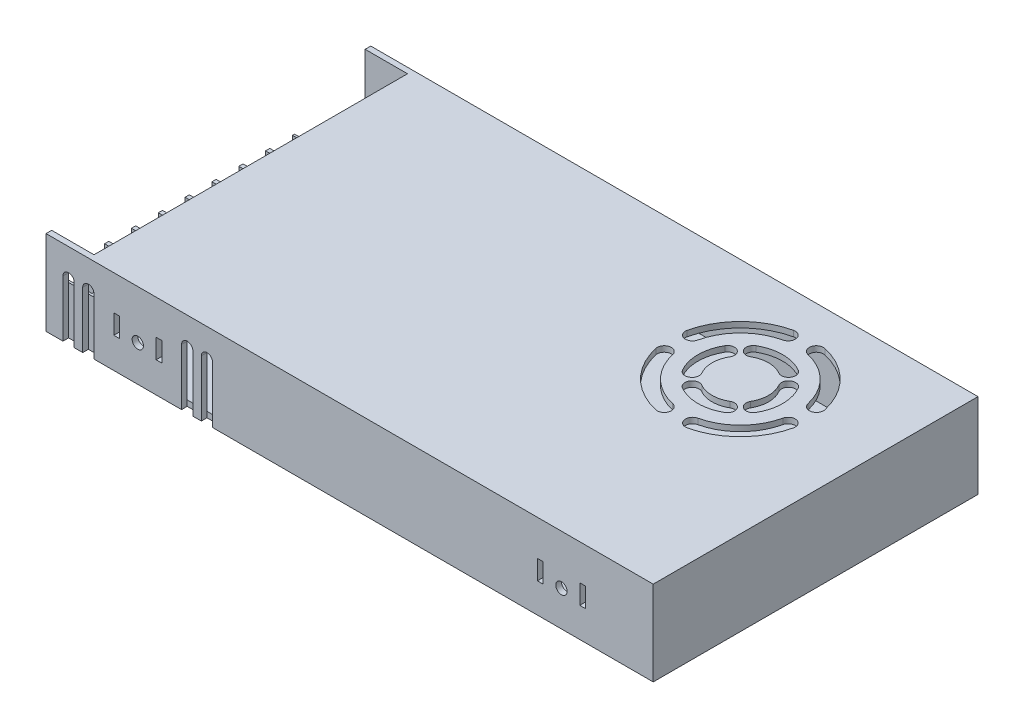
from build123d import *

# Parameters (mm, degrees)
SKETCH1_W              = 215
SKETCH1_H              = 115
BOSS_EXTRUDE1_DEPTH    = 30
SHELL1_T               = -2
CUT_EXTRUDE1_DEPTH     = 28
CIRPATTERN1_COUNT      = 4
SKETCH3_W              = 15
SKETCH3_H              = 111
CUT_EXTRUDE2_DEPTH     = 10
CUT_EXTRUDE3_START     = -20
SKETCH4_R              = 2
CUT_EXTRUDE3_DEPTH     = 11
SKETCH5_W              = 14.5
SKETCH5_H              = 9.5
BOSS_EXTRUDE2_DEPTH    = 15
SKETCH6_W              = 13
SKETCH6_H              = 8
CUT_EXTRUDE4_DEPTH     = 10
SKETCH7_W              = 12
SKETCH7_H              = 7.5
BOSS_EXTRUDE3_DEPTH    = 1
SKETCH8_R              = 3
BOSS_EXTRUDE4_DEPTH    = 2
FILLET1_R              = 1
LPATTERN1_COUNT        = 9
LPATTERN1_PITCH        = 9.5
FILLET1_OF_LPATTERN1_R = 1
SKETCH9_R              = 2
SKETCH9_W              = 2
SKETCH9_H              = 6.9
SKETCH9_W_2            = 2.056016159
CUT_EXTRUDE5_DEPTH     = 2


with BuildPart() as part:
    # Sketch1 → Boss-Extrude1 (new body)
    with BuildSketch(Plane(origin=(0, 0, 0), x_dir=(1, 0, 0), z_dir=(0, 1, 0))):
        Rectangle(SKETCH1_W, SKETCH1_H)
    extrude(amount=BOSS_EXTRUDE1_DEPTH)

    # Shell1
    shell1_openings = [part.faces().sort_by_distance(p)[0] for p in [
        (-107.5, 15, 0),
    ]]
    offset(amount=SHELL1_T, openings=shell1_openings, kind=Kind.INTERSECTION)

    # Sketch2 → Cut-Extrude1 (cut)
    with BuildSketch(Plane(origin=(0, 30, 0), x_dir=(1, 0, 0), z_dir=(0, 1, 0))):
        with BuildLine():
            ThreePointArc((67.55, 33.790381057), (60.05, 35.8), (52.55, 33.790381057))
            ThreePointArc((52.55, 33.790381057), (51.634936491, 30.375317547), (55.05, 29.460254038))
            ThreePointArc((55.05, 29.460254038), (60.05, 30.8), (65.05, 29.460254038))
            ThreePointArc((65.05, 29.460254038), (68.465063509, 30.375317547), (67.55, 33.790381057))
        make_face()
        with BuildLine():
            ThreePointArc((54.494444444, 45.174901076), (42.37233047, 38.47766953), (35.675098924, 26.355555556))
            ThreePointArc((35.675098924, 26.355555556), (37.557033476, 23.362509892), (40.550079139, 25.244444444))
            ThreePointArc((40.550079139, 25.244444444), (45.907864376, 34.942135624), (55.605555556, 40.299920861))
            ThreePointArc((55.605555556, 40.299920861), (57.487490108, 43.292966524), (54.494444444, 45.174901076))
        make_face()
    cut_extrude1 = extrude(amount=-CUT_EXTRUDE1_DEPTH, mode=Mode.SUBTRACT)

    # CirPattern1: Cut-Extrude1 ×4 about axis
    cirpattern1_axis = Axis((60.05, 0, -20.8), (0, 1, 0))
    for i in range(1, CIRPATTERN1_COUNT):
        add(cut_extrude1.rotate(cirpattern1_axis, i * 360 / CIRPATTERN1_COUNT), mode=Mode.SUBTRACT)

    # Sketch3 → Cut-Extrude2 (cut)
    with BuildSketch(Plane(origin=(0, 30, 0), x_dir=(1, 0, 0), z_dir=(0, 1, 0))):
        with Locations((-100, 0)):
            Rectangle(SKETCH3_W, SKETCH3_H)
    extrude(amount=-CUT_EXTRUDE2_DEPTH, mode=Mode.SUBTRACT)

    # Sketch4 → Cut-Extrude3 (cut, through all)
    with BuildSketch(Plane(origin=(0, 30, 0), x_dir=(1, 0, 0), z_dir=(0, 1, 0)).offset(CUT_EXTRUDE3_START)):
        with Locations((-75, 25)):
            Circle(SKETCH4_R)
        with Locations((-75, -25)):
            Circle(SKETCH4_R)
        with Locations((75, -25)):
            Circle(SKETCH4_R)
        with Locations((75, 25)):
            Circle(SKETCH4_R)
    extrude(amount=-CUT_EXTRUDE3_DEPTH, mode=Mode.SUBTRACT)

    # Sketch5 → Boss-Extrude2 (add)
    with BuildSketch(Plane(origin=(0, 2, 0), x_dir=(1, 0, 0), z_dir=(0, 1, 0))):
        with Locations((-99.75, -50.75)):
            Rectangle(SKETCH5_W, SKETCH5_H)
    boss_extrude2 = extrude(amount=BOSS_EXTRUDE2_DEPTH)

    # Sketch6 → Cut-Extrude4 (cut)
    with BuildSketch(Plane(origin=(0, 17, 0), x_dir=(1, 0, 0), z_dir=(0, 1, 0))):
        with Locations((-100.5, -50.75)):
            Rectangle(SKETCH6_W, SKETCH6_H)
    cut_extrude4 = extrude(amount=-CUT_EXTRUDE4_DEPTH, mode=Mode.SUBTRACT)

    # Sketch7 → Boss-Extrude3 (add)
    with BuildSketch(Plane(origin=(0, 7, 0), x_dir=(1, 0, 0), z_dir=(0, 1, 0))):
        with Locations((-100.5, -50.75)):
            Rectangle(SKETCH7_W, SKETCH7_H)
    boss_extrude3 = extrude(amount=BOSS_EXTRUDE3_DEPTH)

    # Sketch8 → Boss-Extrude4 (add)
    with BuildSketch(Plane(origin=(0, 8, 0), x_dir=(1, 0, 0), z_dir=(0, 1, 0))):
        with Locations((-100.5, -50.75)):
            Circle(SKETCH8_R)
    boss_extrude4 = extrude(amount=BOSS_EXTRUDE4_DEPTH)

    # Fillet1
    fillet1_edges = [part.edges().sort_by_distance(p)[0] for p in [
        (-103.5, 10, 50.75),
    ]]
    fillet(fillet1_edges, radius=FILLET1_R)

    # LPattern1: Boss-Extrude2, Cut-Extrude4, Boss-Extrude3, Boss-Extrude4 ×9
    with Locations(*[(0, 0, -i * LPATTERN1_PITCH) for i in range(1, LPATTERN1_COUNT)]):
        add(boss_extrude2)
        add(cut_extrude4, mode=Mode.SUBTRACT)
        add(boss_extrude3)
        add(boss_extrude4)

    # Fillet1 of LPattern1
    fillet1_of_lpattern1_edges = [part.edges().sort_by_distance(p)[0] for p in [
        (-103.5, 10, 41.25),
        (-103.5, 10, 31.75),
        (-103.5, 10, 22.25),
        (-103.5, 10, 12.75),
        (-103.5, 10, 3.25),
        (-103.5, 10, -6.25),
        (-103.5, 10, -15.75),
        (-103.5, 10, -25.25),
    ]]
    fillet(fillet1_of_lpattern1_edges, radius=FILLET1_OF_LPATTERN1_R)

    # Sketch9 → Cut-Extrude5 (cut)
    with BuildSketch(Plane.XY.offset(57.5)):
        with Locations((-75, 12.8)):
            Circle(SKETCH9_R)
        with Locations((75, 12.5)):
            Circle(SKETCH9_R)
        with BuildLine():
            Line((-101.5, 0), (-101.5, 20))
            ThreePointArc((-101.5, 20), (-99.5, 22), (-97.5, 20))
            Line((-97.5, 20), (-97.5, 0))
            Line((-97.5, 0), (-101.5, 0))
        make_face()
        with BuildLine():
            Line((-94.5, 0), (-90.5, 0))
            Line((-90.5, 0), (-90.5, 20))
            ThreePointArc((-90.5, 20), (-92.5, 22), (-94.5, 20))
            Line((-94.5, 20), (-94.5, 0))
        make_face()
        with BuildLine():
            Line((-59.5, 0), (-59.5, 20))
            ThreePointArc((-59.5, 20), (-57.5, 22), (-55.5, 20))
            Line((-55.5, 20), (-55.5, 0))
            Line((-55.5, 0), (-59.5, 0))
        make_face()
        with BuildLine():
            Line((-52.5, 0), (-48.5, 0))
            Line((-48.5, 0), (-48.5, 20))
            ThreePointArc((-48.5, 20), (-50.5, 22), (-52.5, 20))
            Line((-52.5, 20), (-52.5, 0))
        make_face()
        with Locations((-82.5, 14.25)):
            Rectangle(SKETCH9_W, SKETCH9_H)
        with Locations((-67.5, 14.25)):
            Rectangle(SKETCH9_W, SKETCH9_H)
        with Locations((82.52800808, 13.95)):
            Rectangle(SKETCH9_W_2, SKETCH9_H)
        with Locations((67.5, 13.95)):
            Rectangle(SKETCH9_W, SKETCH9_H)
    cut_extrude5 = extrude(amount=-CUT_EXTRUDE5_DEPTH, mode=Mode.SUBTRACT)

    # Mirror2: Cut-Extrude5 across plane
    add(cut_extrude5.mirror(Plane.XY), mode=Mode.SUBTRACT)


solid = part.part
